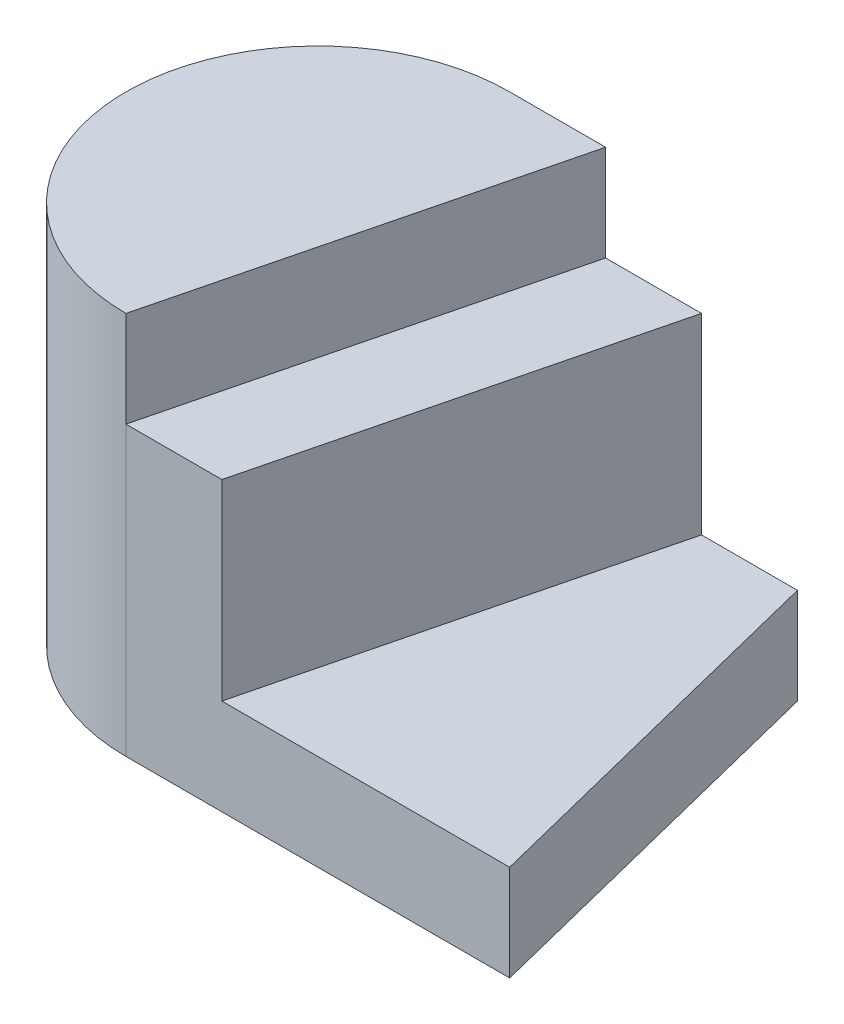
from build123d import *

# Parameters (mm, degrees)
EXTRUDE_2_DEPTH = 4
EXTRUDE_3_DEPTH = 3
EXTRUDE_4_DEPTH = 1


with BuildPart() as part:
    # 草圖1 → 填料-伸長2 (new body)
    with BuildSketch(Plane(origin=(0, 0, 0), x_dir=(1, 0, 0), z_dir=(0, 1, 0))):
        with BuildLine():
            Line((1, 2), (0, 2))
            ThreePointArc((0, 2), (-2, 0), (0, -2))
            Line((0, -2), (1, 2))
        make_face()
    extrude(amount=EXTRUDE_2_DEPTH)

    # 草圖1<4> → 填料-伸長3 (add)
    with BuildSketch(Plane(origin=(0, 0, 0), x_dir=(1, 0, 0), z_dir=(0, 1, 0))):
        Polygon((1, 2), (0, -2), (1, -2), (2, 2), align=None)
    extrude(amount=EXTRUDE_3_DEPTH)

    # 草圖1<5> → 填料-伸長4 (add)
    with BuildSketch(Plane(origin=(0, 0, 0), x_dir=(1, 0, 0), z_dir=(0, 1, 0))):
        Polygon((2, 2), (1, -2), (4, -2), (3, 2), align=None)
    extrude(amount=EXTRUDE_4_DEPTH)


solid = part.part
